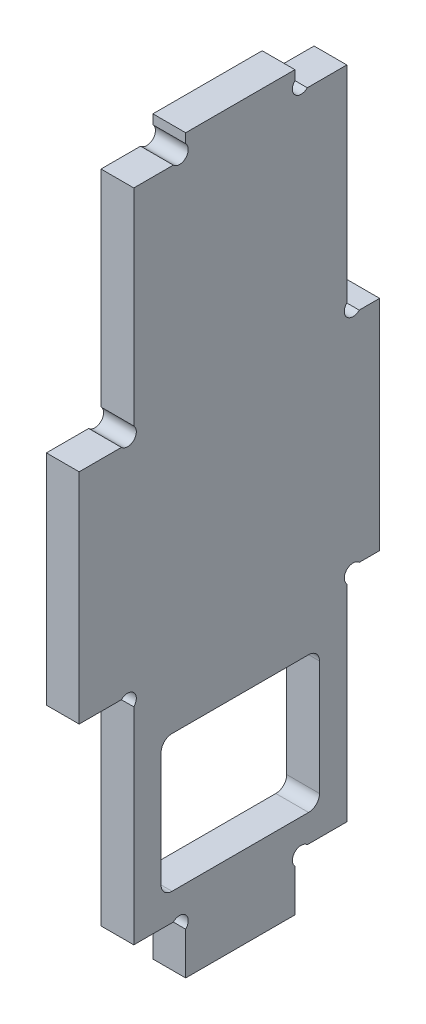
from build123d import *

# Parameters (mm, degrees)
EXTRUSION1_DEPTH        = 6
ESQUISSE2_W             = 29
ESQUISSE2_H             = 25
ENL_V_MAT_EXTRU_1_DEPTH = 7
CONG_1_R                = 2


with BuildPart() as part:
    # Esquisse1 → Extrusion1 (new body)
    with BuildSketch(Plane(origin=(0, 0, 0), x_dir=(0, 0, -1), z_dir=(1, 0, 0))):
        with BuildLine():
            Line((19.5, 7.7372583), (19.5, 0))
            Line((19.5, 0), (39.5, 0))
            Line((39.5, 0), (39.5, 7.7372583))
            ThreePointArc((39.5, 7.7372583), (39.5, 10), (41.7627417, 10))
            Line((41.7627417, 10), (49, 10))
            Line((49, 10), (49, 47.7372583))
            ThreePointArc((49, 47.7372583), (49, 50), (51.2627417, 50))
            Line((51.2627417, 50), (55, 50))
            Line((55, 50), (55, 90))
            Line((55, 90), (51.2627417, 90))
            ThreePointArc((51.2627417, 90), (49, 90), (49, 92.2627417))
            Line((49, 92.2627417), (49, 130))
            Line((49, 130), (41.7627417, 130))
            ThreePointArc((41.7627417, 130), (39.5, 130), (39.5, 132.2627417))
            Line((39.5, 132.2627417), (39.5, 134))
            Line((39.5, 134), (19.5, 134))
            Line((19.5, 134), (19.5, 132.2627417))
            ThreePointArc((19.5, 132.2627417), (19.5, 130), (17.2372583, 130))
            Line((17.2372583, 130), (10, 130))
            Line((10, 130), (10, 92.2627417))
            ThreePointArc((10, 92.2627417), (10, 90), (7.7372583, 90))
            Line((7.7372583, 90), (0, 90))
            Line((0, 90), (0, 50))
            Line((0, 50), (7.7372583, 50))
            ThreePointArc((7.7372583, 50), (10, 50), (10, 47.7372583))
            Line((10, 47.7372583), (10, 10))
            Line((10, 10), (17.2372583, 10))
            ThreePointArc((17.2372583, 10), (19.5, 10), (19.5, 7.7372583))
        make_face()
    extrude(amount=EXTRUSION1_DEPTH)

    # Esquisse2 → Enlèv. mat.-Extru.1 (cut, through all)
    with BuildSketch(Plane(origin=(6, 0, 0), x_dir=(0, 0, -1), z_dir=(1, 0, 0))):
        with Locations((29.5, 27.5)):
            Rectangle(ESQUISSE2_W, ESQUISSE2_H)
    extrude(amount=-ENL_V_MAT_EXTRU_1_DEPTH, mode=Mode.SUBTRACT)

    # Congé1
    cong_1_edges = [part.edges().sort_by_distance(p)[0] for p in [
        (3, 15, -15),
        (3, 40, -15),
        (3, 40, -44),
        (3, 15, -44),
    ]]
    fillet(cong_1_edges, radius=CONG_1_R)


solid = part.part
